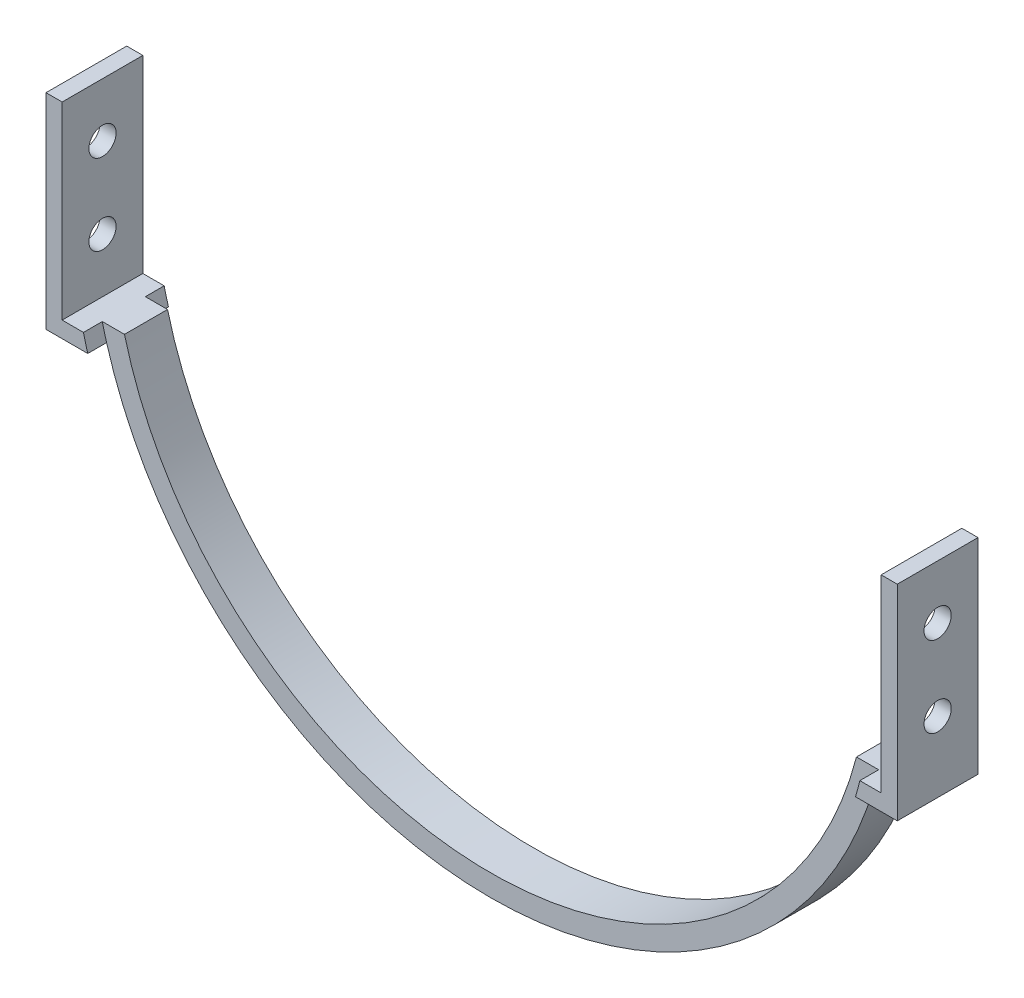
from build123d import *

# Parameters (mm, degrees)
BOSS_EXTRUDE1_DEPTH                 = 4
BOSS_EXTRUDE2_DEPTH                 = 7.5
F_8_0_199_DIAMETER_HOLE1_AT_2_COUNT = 2
F_8_0_199_DIAMETER_HOLE1_AT_2_PITCH = 15


with BuildPart() as part:
    # Sketch1 → Boss-Extrude1 (new, symmetric)
    with BuildSketch(Plane.XY):
        with BuildLine():
            Line((-68.014741233, -17.6), (-72.139067259, -17.6))
            ThreePointArc((-72.139067259, -17.6), (-71.75538681, -19.104174642), (-71.340346404, -20.6))
            ThreePointArc((-71.340346404, -20.6), (0, -74.255), (71.340346404, -20.6))
            ThreePointArc((71.340346404, -20.6), (71.75538681, -19.104174642), (72.139067259, -17.6))
            Line((72.139067259, -17.6), (68.014741233, -17.6))
            ThreePointArc((68.014741233, -17.6), (0, -70.255), (-68.014741233, -17.6))
        make_face()
    extrude(amount=BOSS_EXTRUDE1_DEPTH, both=True)

    # Sketch1_5 → Boss-Extrude2 (add, symmetric)
    with BuildSketch(Plane.XY):
        with BuildLine():
            ThreePointArc((-71.340346404, -20.6), (-71.75538681, -19.104174642), (-72.139067259, -17.6))
            Line((-72.139067259, -17.6), (-76.1, -17.6))
            Line((-76.1, -17.6), (-76.1, 17.5))
            Line((-76.1, 17.5), (-79.1, 17.5))
            Line((-79.1, 17.5), (-79.1, -20.6))
            Line((-79.1, -20.6), (-71.340346404, -20.6))
        make_face()
        with BuildLine():
            ThreePointArc((72.139067259, -17.6), (71.75538681, -19.104174642), (71.340346404, -20.6))
            Line((71.340346404, -20.6), (79.1, -20.6))
            Line((79.1, -20.6), (79.1, 17.5))
            Line((79.1, 17.5), (76.1, 17.5))
            Line((76.1, 17.5), (76.1, -17.6))
            Line((76.1, -17.6), (72.139067259, -17.6))
        make_face()
    extrude(amount=BOSS_EXTRUDE2_DEPTH, both=True)

    # Sketch4 → 8 _0.199_ Diameter Hole1 (revolve, cut)
    with BuildSketch(Plane(origin=(-79.1, 7.5, 0), x_dir=(0, 0, 1), z_dir=(0, 1, 0))):
        Polygon((0, 0), (0, 13), (2.5273, 11.481444958), (2.5273, 0), align=None)
    f_8_0_199_diameter_hole1 = revolve(axis=Axis((-85.45, 7.5, 0), (1, 0, 0)), mode=Mode.SUBTRACT)

    # 8 _0.199_ Diameter Hole1 at 2: 8 _0.199_ Diameter Hole1 ×2
    with Locations(*[(0, -i * F_8_0_199_DIAMETER_HOLE1_AT_2_PITCH, 0) for i in range(1, F_8_0_199_DIAMETER_HOLE1_AT_2_COUNT)]):
        add(f_8_0_199_diameter_hole1, mode=Mode.SUBTRACT)

    # Mirror1: 8 _0.199_ Diameter Hole1 across plane
    add(f_8_0_199_diameter_hole1.mirror(Plane(origin=(0, 0, 0), x_dir=(0, 0, 1), z_dir=(1, 0, 0))), mode=Mode.SUBTRACT)

    # Mirror1 copy 1 sketch → Mirror1 copy 1 (revolve, cut)
    with BuildSketch(Plane(origin=(79.1, -7.5, 0), x_dir=(0, 0, 1), z_dir=(0, 1, 0))):
        Polygon((0, 0), (0, -13), (2.5273, -11.481444958), (2.5273, 0), align=None)
    revolve(axis=Axis((85.45, -7.5, 0), (1, 0, 0)), mode=Mode.SUBTRACT)


solid = part.part
